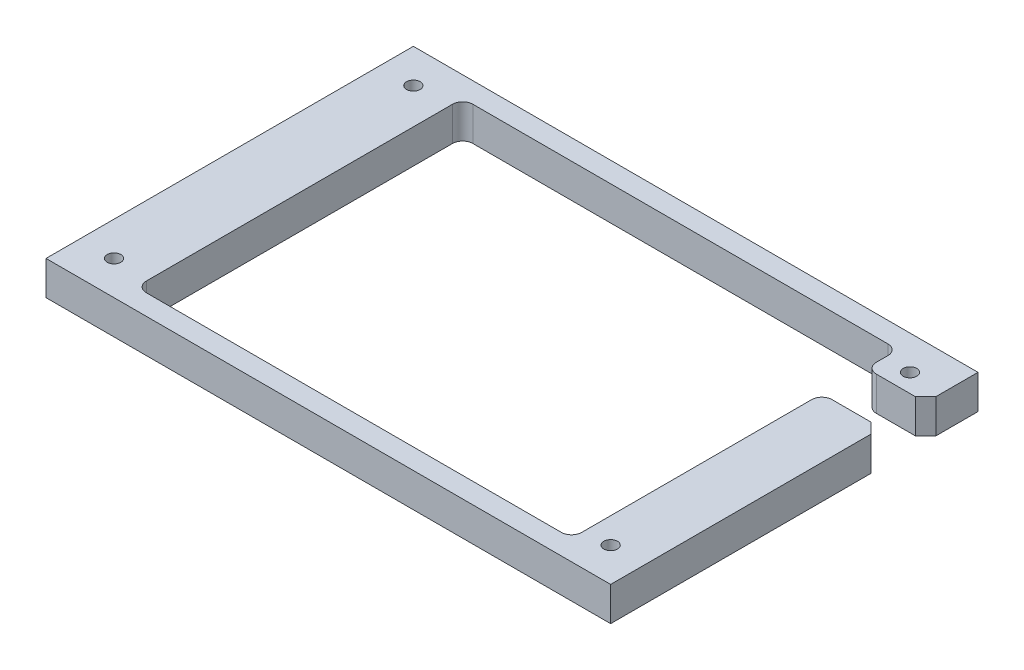
from build123d import *

# Parameters (mm, degrees)
SKETCH_1_W             = 166
SKETCH_1_H             = 108
EXTRUDE_1_DEPTH        = 10
SKETCH_2_R             = 2
CUT_EXTRUDE_834_DEPTH  = 11
SKETCH_4_W             = 128
SKETCH_4_H             = 96
CUT_EXTRUDE_1103_DEPTH = 11
SKETCH_5_W             = 17.5
SKETCH_5_H             = 13
USB_DEPTH              = 11
FILLET_1_R             = 3
CHAMFER_1_SIZE         = 3
FILLET_2_R             = 3


with BuildPart() as part:
    # Эскиз1 → Бобышка-Вытянуть1 (new body)
    with BuildSketch(Plane(origin=(0, 0, 0), x_dir=(1, 0, 0), z_dir=(0, 1, 0))):
        Rectangle(SKETCH_1_W, SKETCH_1_H)
    extrude(amount=EXTRUDE_1_DEPTH)

    # Эскиз2 → Cut-Extrude 834 (cut, through all)
    with BuildSketch(Plane(origin=(0, 10, 0), x_dir=(1, 0, 0), z_dir=(0, 1, 0))):
        with Locations((-73, 44)):
            Circle(SKETCH_2_R)
        with Locations((73, 44)):
            Circle(SKETCH_2_R)
        with Locations((-73, -44)):
            Circle(SKETCH_2_R)
        with Locations((73, -44)):
            Circle(SKETCH_2_R)
    extrude(amount=-CUT_EXTRUDE_834_DEPTH, mode=Mode.SUBTRACT)

    # Эскиз4 → Cut-Extrude 1103 (cut, through all)
    with BuildSketch(Plane(origin=(0, 10, 0), x_dir=(1, 0, 0), z_dir=(0, 1, 0))):
        with Locations((1.5, 0)):
            Rectangle(SKETCH_4_W, SKETCH_4_H)
    extrude(amount=-CUT_EXTRUDE_1103_DEPTH, mode=Mode.SUBTRACT)

    # Эскиз5 → usb (cut, through all)
    with BuildSketch(Plane(origin=(0, 10, 0), x_dir=(1, 0, 0), z_dir=(0, 1, 0))):
        with Locations((74.25, 32.1)):
            Rectangle(SKETCH_5_W, SKETCH_5_H)
    extrude(amount=-USB_DEPTH, mode=Mode.SUBTRACT)

    # Скругление1
    fillet_1_edges = [part.edges().sort_by_distance(p)[0] for p in [
        (65.5, 5, -48),
        (65.5, 5, 48),
        (-62.5, 5, 48),
        (-62.5, 5, -48),
    ]]
    fillet(fillet_1_edges, radius=FILLET_1_R)

    # Фаска1
    chamfer_1_edges = [part.edges().sort_by_distance(p)[0] for p in [
        (83, 5, -38.6),
        (83, 5, -25.6),
    ]]
    chamfer(chamfer_1_edges, length=CHAMFER_1_SIZE)

    # Скругление2
    fillet_2_edges = [part.edges().sort_by_distance(p)[0] for p in [
        (65.5, 5, -25.6),
        (65.5, 5, -38.6),
    ]]
    fillet(fillet_2_edges, radius=FILLET_2_R)


solid = part.part
